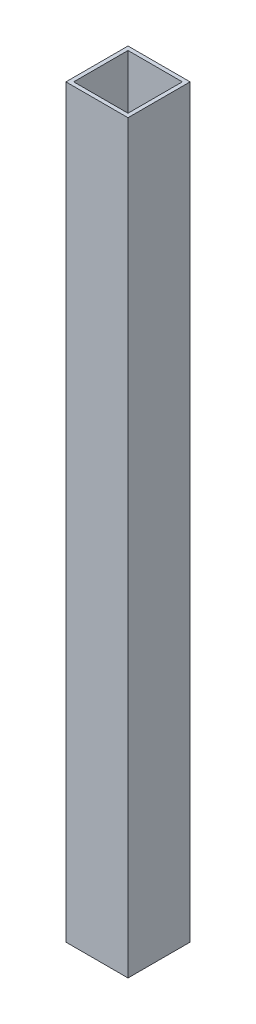
from build123d import *

# Parameters (mm, degrees)
SKETCH1_W           = 25.4
SKETCH1_H           = 25.4
SKETCH1_W_2         = 22.225
SKETCH1_H_2         = 22.225
BOSS_EXTRUDE1_DEPTH = 304.8


with BuildPart() as part:
    # Sketch1 → Boss-Extrude1 (new body)
    with BuildSketch(Plane(origin=(0, 0, 0), x_dir=(1, 0, 0), z_dir=(0, 1, 0))):
        Rectangle(SKETCH1_W, SKETCH1_H)
        Rectangle(SKETCH1_W_2, SKETCH1_H_2, mode=Mode.SUBTRACT)
    extrude(amount=BOSS_EXTRUDE1_DEPTH)


solid = part.part
